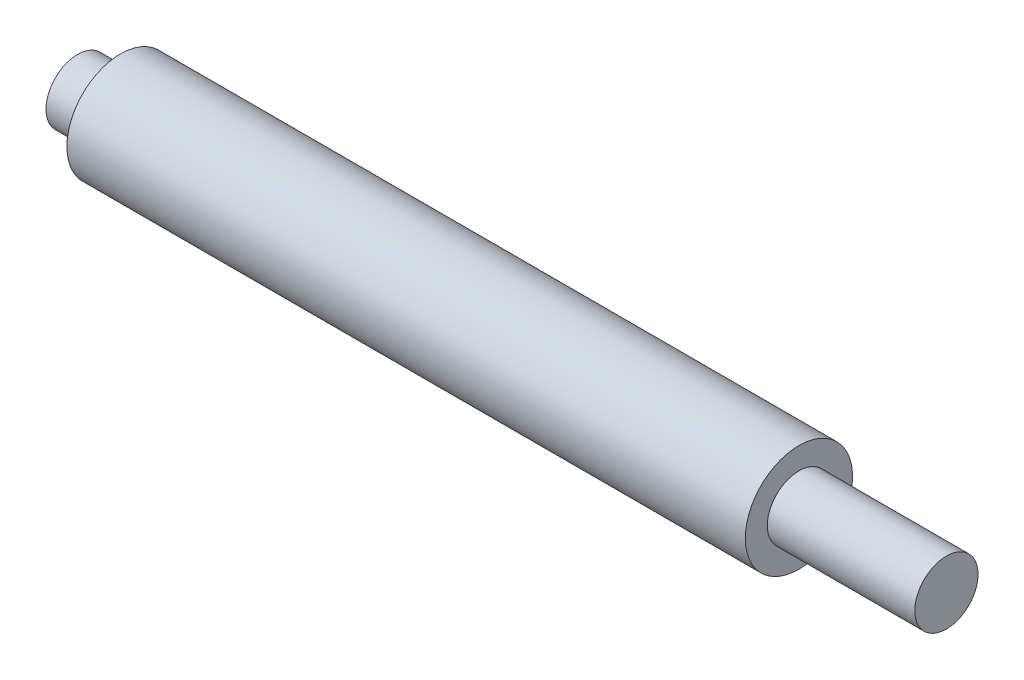
from build123d import *


with BuildPart() as part:
    # Sketch1 → Revolve1 (revolve)
    with BuildSketch(Plane.XY):
        Polygon((0, 0), (81, 0), (81, 2.95), (67.25, 2.95), (67.25, 5), (4, 5), (4, 2.95), (0, 2.95), align=None)
    revolve(axis=Axis((0, 0, 0), (1, 0, 0)))


solid = part.part
